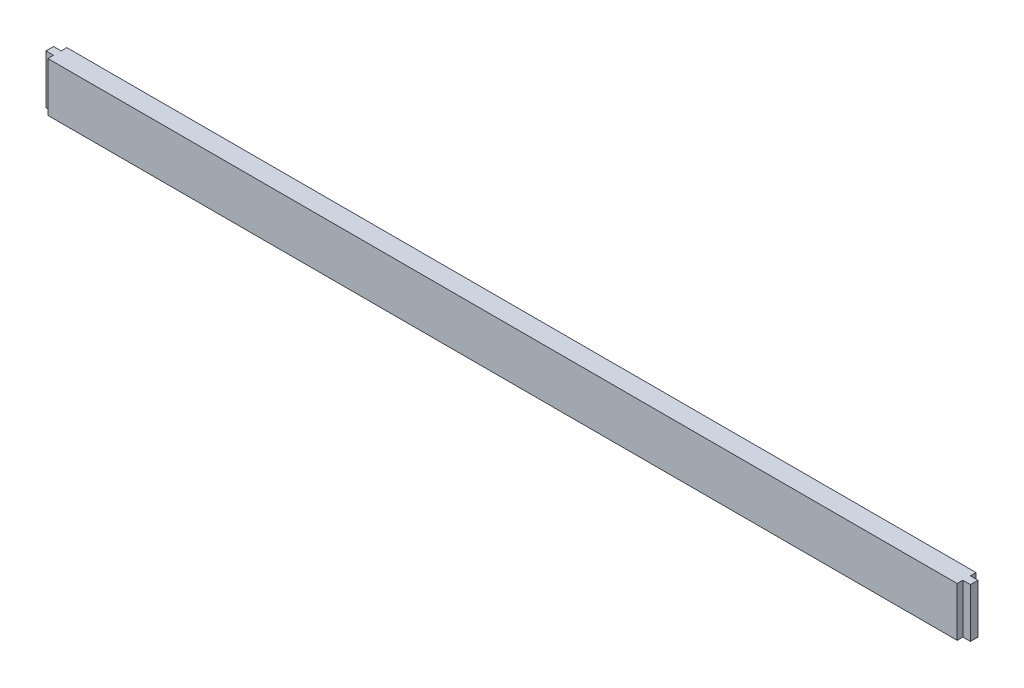
from build123d import *

# Parameters (mm, degrees)
SKETCH1_W           = 774.7
SKETCH1_H           = 41.275
BOSS_EXTRUDE1_DEPTH = 15.875
SKETCH2_W           = 6.35
SKETCH2_H           = 4.7625
CUT_EXTRUDE1_DEPTH  = 42.275


with BuildPart() as part:
    # Sketch1 → Boss-Extrude1 (new body)
    with BuildSketch(Plane.XY):
        with Locations((387.35, 20.6375)):
            Rectangle(SKETCH1_W, SKETCH1_H)
    extrude(amount=BOSS_EXTRUDE1_DEPTH)

    # Sketch2 → Cut-Extrude1 (cut, through all)
    with BuildSketch(Plane(origin=(0, 41.275, 0), x_dir=(1, 0, 0), z_dir=(0, 1, 0))):
        with Locations((771.525, -13.49375)):
            Rectangle(SKETCH2_W, SKETCH2_H)
        with Locations((771.525, -2.38125)):
            Rectangle(SKETCH2_W, SKETCH2_H)
        with Locations((3.175, -2.38125)):
            Rectangle(SKETCH2_W, SKETCH2_H)
        with Locations((3.175, -13.49375)):
            Rectangle(SKETCH2_W, SKETCH2_H)
    extrude(amount=-CUT_EXTRUDE1_DEPTH, mode=Mode.SUBTRACT)


solid = part.part
